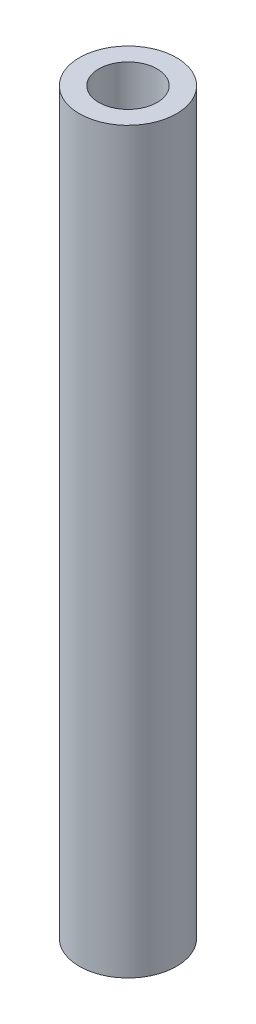
from build123d import *

# Parameters (mm, degrees)
SKETCH_1_R      = 2.5
SKETCH_1_R_2    = 1.5
EXTRUDE_1_DEPTH = 19


with BuildPart() as part:
    # 草图1 → 凸台-拉伸1 (new body, symmetric)
    with BuildSketch(Plane(origin=(0, 0, 0), x_dir=(1, 0, 0), z_dir=(0, 1, 0))):
        Circle(SKETCH_1_R)
        Circle(SKETCH_1_R_2, mode=Mode.SUBTRACT)
    extrude(amount=EXTRUDE_1_DEPTH, both=True)


solid = part.part
